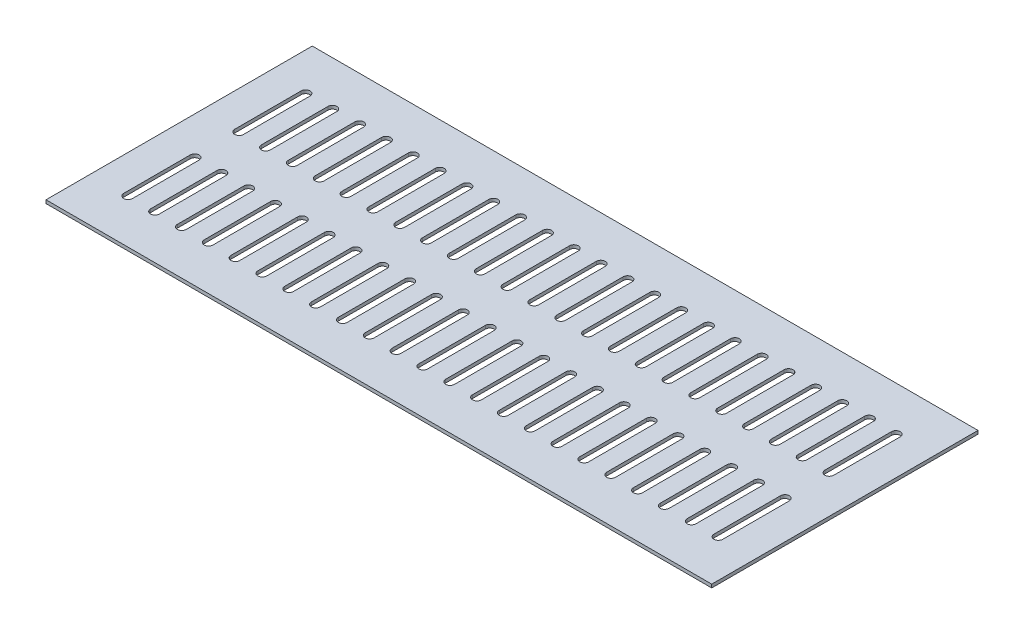
from build123d import *

# Parameters (mm, degrees)
IZIM1_W                     = 600
IZIM1_H                     = 240
Y_KSEKLIK_EKSTR_ZYON1_DEPTH = 3


with BuildPart() as part:
    # Çizim1 → Yükseklik-Ekstrüzyon1 (new body)
    with BuildSketch(Plane(origin=(0, 0, 0), x_dir=(1, 0, 0), z_dir=(0, 1, 0))):
        with Locations((300, -120)):
            Rectangle(IZIM1_W, IZIM1_H)
        with BuildLine():
            Line((38, -40), (38, -100))
            ThreePointArc((38, -100), (34, -104), (30, -100))
            Line((30, -100), (30, -40))
            ThreePointArc((30, -40), (34, -36), (38, -40))
        make_face(mode=Mode.SUBTRACT)
        with BuildLine():
            Line((38, -140), (38, -200))
            ThreePointArc((38, -200), (34, -204), (30, -200))
            Line((30, -200), (30, -140))
            ThreePointArc((30, -140), (34, -136), (38, -140))
        make_face(mode=Mode.SUBTRACT)
        with BuildLine():
            Line((54.181818182, -40), (54.181818182, -100))
            ThreePointArc((54.181818182, -100), (58.181818182, -104), (62.181818182, -100))
            Line((62.181818182, -100), (62.181818182, -40))
            ThreePointArc((62.181818182, -40), (58.181818182, -36), (54.181818182, -40))
        make_face(mode=Mode.SUBTRACT)
        with BuildLine():
            Line((54.181818182, -140), (54.181818182, -200))
            ThreePointArc((54.181818182, -200), (58.181818182, -204), (62.181818182, -200))
            Line((62.181818182, -200), (62.181818182, -140))
            ThreePointArc((62.181818182, -140), (58.181818182, -136), (54.181818182, -140))
        make_face(mode=Mode.SUBTRACT)
        with BuildLine():
            Line((78.363636364, -40), (78.363636364, -100))
            ThreePointArc((78.363636364, -100), (82.363636364, -104), (86.363636364, -100))
            Line((86.363636364, -100), (86.363636364, -40))
            ThreePointArc((86.363636364, -40), (82.363636364, -36), (78.363636364, -40))
        make_face(mode=Mode.SUBTRACT)
        with BuildLine():
            Line((78.363636364, -140), (78.363636364, -200))
            ThreePointArc((78.363636364, -200), (82.363636364, -204), (86.363636364, -200))
            Line((86.363636364, -200), (86.363636364, -140))
            ThreePointArc((86.363636364, -140), (82.363636364, -136), (78.363636364, -140))
        make_face(mode=Mode.SUBTRACT)
        with BuildLine():
            Line((102.545454545, -40), (102.545454545, -100))
            ThreePointArc((102.545454545, -100), (106.545454545, -104), (110.545454545, -100))
            Line((110.545454545, -100), (110.545454545, -40))
            ThreePointArc((110.545454545, -40), (106.545454545, -36), (102.545454545, -40))
        make_face(mode=Mode.SUBTRACT)
        with BuildLine():
            Line((102.545454545, -140), (102.545454545, -200))
            ThreePointArc((102.545454545, -200), (106.545454545, -204), (110.545454545, -200))
            Line((110.545454545, -200), (110.545454545, -140))
            ThreePointArc((110.545454545, -140), (106.545454545, -136), (102.545454545, -140))
        make_face(mode=Mode.SUBTRACT)
        with BuildLine():
            Line((126.727272727, -40), (126.727272727, -100))
            ThreePointArc((126.727272727, -100), (130.727272727, -104), (134.727272727, -100))
            Line((134.727272727, -100), (134.727272727, -40))
            ThreePointArc((134.727272727, -40), (130.727272727, -36), (126.727272727, -40))
        make_face(mode=Mode.SUBTRACT)
        with BuildLine():
            Line((126.727272727, -140), (126.727272727, -200))
            ThreePointArc((126.727272727, -200), (130.727272727, -204), (134.727272727, -200))
            Line((134.727272727, -200), (134.727272727, -140))
            ThreePointArc((134.727272727, -140), (130.727272727, -136), (126.727272727, -140))
        make_face(mode=Mode.SUBTRACT)
        with BuildLine():
            Line((150.909090909, -40), (150.909090909, -100))
            ThreePointArc((150.909090909, -100), (154.909090909, -104), (158.909090909, -100))
            Line((158.909090909, -100), (158.909090909, -40))
            ThreePointArc((158.909090909, -40), (154.909090909, -36), (150.909090909, -40))
        make_face(mode=Mode.SUBTRACT)
        with BuildLine():
            Line((150.909090909, -140), (150.909090909, -200))
            ThreePointArc((150.909090909, -200), (154.909090909, -204), (158.909090909, -200))
            Line((158.909090909, -200), (158.909090909, -140))
            ThreePointArc((158.909090909, -140), (154.909090909, -136), (150.909090909, -140))
        make_face(mode=Mode.SUBTRACT)
        with BuildLine():
            Line((175.090909091, -40), (175.090909091, -100))
            ThreePointArc((175.090909091, -100), (179.090909091, -104), (183.090909091, -100))
            Line((183.090909091, -100), (183.090909091, -40))
            ThreePointArc((183.090909091, -40), (179.090909091, -36), (175.090909091, -40))
        make_face(mode=Mode.SUBTRACT)
        with BuildLine():
            Line((175.090909091, -140), (175.090909091, -200))
            ThreePointArc((175.090909091, -200), (179.090909091, -204), (183.090909091, -200))
            Line((183.090909091, -200), (183.090909091, -140))
            ThreePointArc((183.090909091, -140), (179.090909091, -136), (175.090909091, -140))
        make_face(mode=Mode.SUBTRACT)
        with BuildLine():
            Line((199.272727273, -40), (199.272727273, -100))
            ThreePointArc((199.272727273, -100), (203.272727273, -104), (207.272727273, -100))
            Line((207.272727273, -100), (207.272727273, -40))
            ThreePointArc((207.272727273, -40), (203.272727273, -36), (199.272727273, -40))
        make_face(mode=Mode.SUBTRACT)
        with BuildLine():
            Line((199.272727273, -140), (199.272727273, -200))
            ThreePointArc((199.272727273, -200), (203.272727273, -204), (207.272727273, -200))
            Line((207.272727273, -200), (207.272727273, -140))
            ThreePointArc((207.272727273, -140), (203.272727273, -136), (199.272727273, -140))
        make_face(mode=Mode.SUBTRACT)
        with BuildLine():
            Line((223.454545455, -40), (223.454545455, -100))
            ThreePointArc((223.454545455, -100), (227.454545455, -104), (231.454545455, -100))
            Line((231.454545455, -100), (231.454545455, -40))
            ThreePointArc((231.454545455, -40), (227.454545455, -36), (223.454545455, -40))
        make_face(mode=Mode.SUBTRACT)
        with BuildLine():
            Line((223.454545455, -140), (223.454545455, -200))
            ThreePointArc((223.454545455, -200), (227.454545455, -204), (231.454545455, -200))
            Line((231.454545455, -200), (231.454545455, -140))
            ThreePointArc((231.454545455, -140), (227.454545455, -136), (223.454545455, -140))
        make_face(mode=Mode.SUBTRACT)
        with BuildLine():
            Line((247.636363636, -40), (247.636363636, -100))
            ThreePointArc((247.636363636, -100), (251.636363636, -104), (255.636363636, -100))
            Line((255.636363636, -100), (255.636363636, -40))
            ThreePointArc((255.636363636, -40), (251.636363636, -36), (247.636363636, -40))
        make_face(mode=Mode.SUBTRACT)
        with BuildLine():
            Line((247.636363636, -140), (247.636363636, -200))
            ThreePointArc((247.636363636, -200), (251.636363636, -204), (255.636363636, -200))
            Line((255.636363636, -200), (255.636363636, -140))
            ThreePointArc((255.636363636, -140), (251.636363636, -136), (247.636363636, -140))
        make_face(mode=Mode.SUBTRACT)
        with BuildLine():
            Line((271.818181818, -40), (271.818181818, -100))
            ThreePointArc((271.818181818, -100), (275.818181818, -104), (279.818181818, -100))
            Line((279.818181818, -100), (279.818181818, -40))
            ThreePointArc((279.818181818, -40), (275.818181818, -36), (271.818181818, -40))
        make_face(mode=Mode.SUBTRACT)
        with BuildLine():
            Line((271.818181818, -140), (271.818181818, -200))
            ThreePointArc((271.818181818, -200), (275.818181818, -204), (279.818181818, -200))
            Line((279.818181818, -200), (279.818181818, -140))
            ThreePointArc((279.818181818, -140), (275.818181818, -136), (271.818181818, -140))
        make_face(mode=Mode.SUBTRACT)
        with BuildLine():
            Line((296, -40), (296, -100))
            ThreePointArc((296, -100), (300, -104), (304, -100))
            Line((304, -100), (304, -40))
            ThreePointArc((304, -40), (300, -36), (296, -40))
        make_face(mode=Mode.SUBTRACT)
        with BuildLine():
            Line((296, -140), (296, -200))
            ThreePointArc((296, -200), (300, -204), (304, -200))
            Line((304, -200), (304, -140))
            ThreePointArc((304, -140), (300, -136), (296, -140))
        make_face(mode=Mode.SUBTRACT)
        with BuildLine():
            Line((320.181818182, -40), (320.181818182, -100))
            ThreePointArc((320.181818182, -100), (324.181818182, -104), (328.181818182, -100))
            Line((328.181818182, -100), (328.181818182, -40))
            ThreePointArc((328.181818182, -40), (324.181818182, -36), (320.181818182, -40))
        make_face(mode=Mode.SUBTRACT)
        with BuildLine():
            Line((320.181818182, -140), (320.181818182, -200))
            ThreePointArc((320.181818182, -200), (324.181818182, -204), (328.181818182, -200))
            Line((328.181818182, -200), (328.181818182, -140))
            ThreePointArc((328.181818182, -140), (324.181818182, -136), (320.181818182, -140))
        make_face(mode=Mode.SUBTRACT)
        with BuildLine():
            Line((344.363636364, -40), (344.363636364, -100))
            ThreePointArc((344.363636364, -100), (348.363636364, -104), (352.363636364, -100))
            Line((352.363636364, -100), (352.363636364, -40))
            ThreePointArc((352.363636364, -40), (348.363636364, -36), (344.363636364, -40))
        make_face(mode=Mode.SUBTRACT)
        with BuildLine():
            Line((344.363636364, -140), (344.363636364, -200))
            ThreePointArc((344.363636364, -200), (348.363636364, -204), (352.363636364, -200))
            Line((352.363636364, -200), (352.363636364, -140))
            ThreePointArc((352.363636364, -140), (348.363636364, -136), (344.363636364, -140))
        make_face(mode=Mode.SUBTRACT)
        with BuildLine():
            Line((368.545454545, -40), (368.545454545, -100))
            ThreePointArc((368.545454545, -100), (372.545454545, -104), (376.545454545, -100))
            Line((376.545454545, -100), (376.545454545, -40))
            ThreePointArc((376.545454545, -40), (372.545454545, -36), (368.545454545, -40))
        make_face(mode=Mode.SUBTRACT)
        with BuildLine():
            Line((368.545454545, -140), (368.545454545, -200))
            ThreePointArc((368.545454545, -200), (372.545454545, -204), (376.545454545, -200))
            Line((376.545454545, -200), (376.545454545, -140))
            ThreePointArc((376.545454545, -140), (372.545454545, -136), (368.545454545, -140))
        make_face(mode=Mode.SUBTRACT)
        with BuildLine():
            Line((392.727272727, -40), (392.727272727, -100))
            ThreePointArc((392.727272727, -100), (396.727272727, -104), (400.727272727, -100))
            Line((400.727272727, -100), (400.727272727, -40))
            ThreePointArc((400.727272727, -40), (396.727272727, -36), (392.727272727, -40))
        make_face(mode=Mode.SUBTRACT)
        with BuildLine():
            Line((392.727272727, -140), (392.727272727, -200))
            ThreePointArc((392.727272727, -200), (396.727272727, -204), (400.727272727, -200))
            Line((400.727272727, -200), (400.727272727, -140))
            ThreePointArc((400.727272727, -140), (396.727272727, -136), (392.727272727, -140))
        make_face(mode=Mode.SUBTRACT)
        with BuildLine():
            Line((416.909090909, -40), (416.909090909, -100))
            ThreePointArc((416.909090909, -100), (420.909090909, -104), (424.909090909, -100))
            Line((424.909090909, -100), (424.909090909, -40))
            ThreePointArc((424.909090909, -40), (420.909090909, -36), (416.909090909, -40))
        make_face(mode=Mode.SUBTRACT)
        with BuildLine():
            Line((416.909090909, -140), (416.909090909, -200))
            ThreePointArc((416.909090909, -200), (420.909090909, -204), (424.909090909, -200))
            Line((424.909090909, -200), (424.909090909, -140))
            ThreePointArc((424.909090909, -140), (420.909090909, -136), (416.909090909, -140))
        make_face(mode=Mode.SUBTRACT)
        with BuildLine():
            Line((441.090909091, -40), (441.090909091, -100))
            ThreePointArc((441.090909091, -100), (445.090909091, -104), (449.090909091, -100))
            Line((449.090909091, -100), (449.090909091, -40))
            ThreePointArc((449.090909091, -40), (445.090909091, -36), (441.090909091, -40))
        make_face(mode=Mode.SUBTRACT)
        with BuildLine():
            Line((441.090909091, -140), (441.090909091, -200))
            ThreePointArc((441.090909091, -200), (445.090909091, -204), (449.090909091, -200))
            Line((449.090909091, -200), (449.090909091, -140))
            ThreePointArc((449.090909091, -140), (445.090909091, -136), (441.090909091, -140))
        make_face(mode=Mode.SUBTRACT)
        with BuildLine():
            Line((465.272727273, -40), (465.272727273, -100))
            ThreePointArc((465.272727273, -100), (469.272727273, -104), (473.272727273, -100))
            Line((473.272727273, -100), (473.272727273, -40))
            ThreePointArc((473.272727273, -40), (469.272727273, -36), (465.272727273, -40))
        make_face(mode=Mode.SUBTRACT)
        with BuildLine():
            Line((465.272727273, -140), (465.272727273, -200))
            ThreePointArc((465.272727273, -200), (469.272727273, -204), (473.272727273, -200))
            Line((473.272727273, -200), (473.272727273, -140))
            ThreePointArc((473.272727273, -140), (469.272727273, -136), (465.272727273, -140))
        make_face(mode=Mode.SUBTRACT)
        with BuildLine():
            Line((489.454545455, -40), (489.454545455, -100))
            ThreePointArc((489.454545455, -100), (493.454545455, -104), (497.454545455, -100))
            Line((497.454545455, -100), (497.454545455, -40))
            ThreePointArc((497.454545455, -40), (493.454545455, -36), (489.454545455, -40))
        make_face(mode=Mode.SUBTRACT)
        with BuildLine():
            Line((489.454545455, -140), (489.454545455, -200))
            ThreePointArc((489.454545455, -200), (493.454545455, -204), (497.454545455, -200))
            Line((497.454545455, -200), (497.454545455, -140))
            ThreePointArc((497.454545455, -140), (493.454545455, -136), (489.454545455, -140))
        make_face(mode=Mode.SUBTRACT)
        with BuildLine():
            Line((513.636363636, -40), (513.636363636, -100))
            ThreePointArc((513.636363636, -100), (517.636363636, -104), (521.636363636, -100))
            Line((521.636363636, -100), (521.636363636, -40))
            ThreePointArc((521.636363636, -40), (517.636363636, -36), (513.636363636, -40))
        make_face(mode=Mode.SUBTRACT)
        with BuildLine():
            Line((513.636363636, -140), (513.636363636, -200))
            ThreePointArc((513.636363636, -200), (517.636363636, -204), (521.636363636, -200))
            Line((521.636363636, -200), (521.636363636, -140))
            ThreePointArc((521.636363636, -140), (517.636363636, -136), (513.636363636, -140))
        make_face(mode=Mode.SUBTRACT)
        with BuildLine():
            Line((537.818181818, -40), (537.818181818, -100))
            ThreePointArc((537.818181818, -100), (541.818181818, -104), (545.818181818, -100))
            Line((545.818181818, -100), (545.818181818, -40))
            ThreePointArc((545.818181818, -40), (541.818181818, -36), (537.818181818, -40))
        make_face(mode=Mode.SUBTRACT)
        with BuildLine():
            Line((537.818181818, -140), (537.818181818, -200))
            ThreePointArc((537.818181818, -200), (541.818181818, -204), (545.818181818, -200))
            Line((545.818181818, -200), (545.818181818, -140))
            ThreePointArc((545.818181818, -140), (541.818181818, -136), (537.818181818, -140))
        make_face(mode=Mode.SUBTRACT)
        with BuildLine():
            Line((562, -40), (562, -100))
            ThreePointArc((562, -100), (566, -104), (570, -100))
            Line((570, -100), (570, -40))
            ThreePointArc((570, -40), (566, -36), (562, -40))
        make_face(mode=Mode.SUBTRACT)
        with BuildLine():
            Line((562, -140), (562, -200))
            ThreePointArc((562, -200), (566, -204), (570, -200))
            Line((570, -200), (570, -140))
            ThreePointArc((570, -140), (566, -136), (562, -140))
        make_face(mode=Mode.SUBTRACT)
    extrude(amount=Y_KSEKLIK_EKSTR_ZYON1_DEPTH)


solid = part.part
